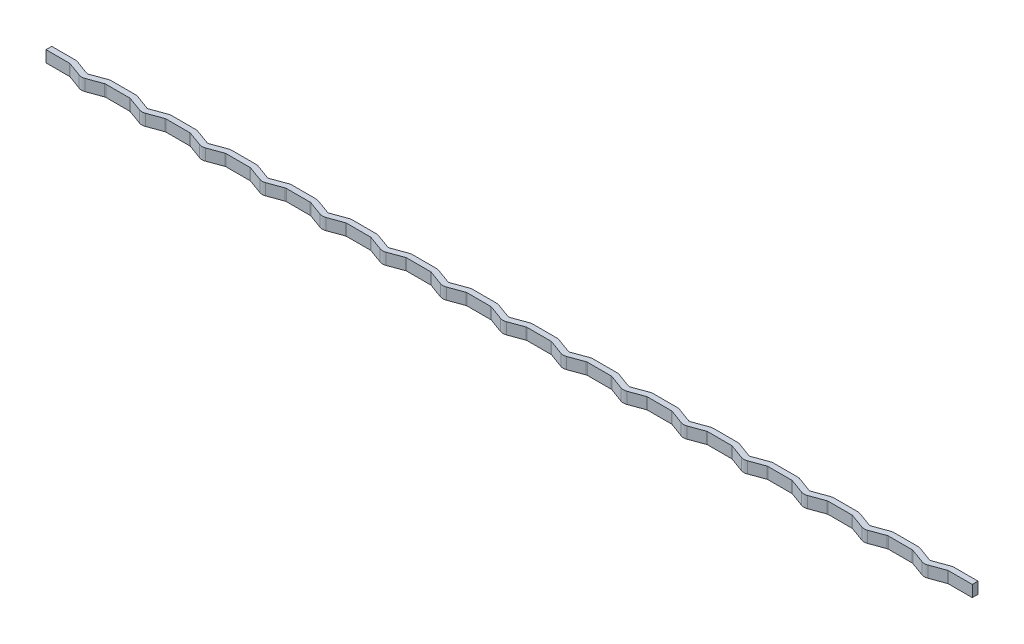
from build123d import *

# Parameters (mm, degrees)
BOSS_EXTRUDE1_DEPTH = 2
LPATTERN1_COUNT     = 15
LPATTERN1_PITCH     = 10.5
BOSS_EXTRUDE2_START = -157.5
SKETCH2_W           = 1
SKETCH2_H           = 2
BOSS_EXTRUDE2_DEPTH = 4.073673019


with BuildPart() as part:
    # Sketch1 → Boss-Extrude1 (new body)
    with BuildSketch(Plane(origin=(0, 0, 0), x_dir=(1, 0, 0), z_dir=(0, 1, 0))):
        with BuildLine():
            Line((0, -0.5), (4.073673019, -0.5))
            ThreePointArc((4.073673019, -0.5), (4.160497108, -0.507596123), (4.244683091, -0.53015369))
            Line((4.244683091, -0.53015369), (6.736969785, -1.437271862))
            ThreePointArc((6.736969785, -1.437271862), (7.25, -1.52773293), (7.763030215, -1.437271862))
            Line((7.763030215, -1.437271862), (10.255316909, -0.53015369))
            ThreePointArc((10.255316909, -0.53015369), (10.339502892, -0.507596123), (10.426326981, -0.5))
            Line((10.426326981, -0.5), (10.75, -0.5))
            Line((10.75, -0.5), (10.75, 0.5))
            Line((10.75, 0.5), (10.426326981, 0.5))
            ThreePointArc((10.426326981, 0.5), (10.165854714, 0.47721163), (9.913296766, 0.409538931))
            Line((9.913296766, 0.409538931), (7.421010072, -0.497579241))
            ThreePointArc((7.421010072, -0.497579241), (7.25, -0.52773293), (7.078989928, -0.497579241))
            Line((7.078989928, -0.497579241), (4.586703234, 0.409538931))
            ThreePointArc((4.586703234, 0.409538931), (4.334145286, 0.47721163), (4.073673019, 0.5))
            Line((4.073673019, 0.5), (0, 0.5))
            Line((0, 0.5), (0, -0.5))
        make_face()
    boss_extrude1 = extrude(amount=BOSS_EXTRUDE1_DEPTH)

    # LPattern1: Boss-Extrude1 ×15
    with Locations(*[(i * LPATTERN1_PITCH, 0, 0) for i in range(1, LPATTERN1_COUNT)]):
        add(boss_extrude1)

    # Sketch2 → Boss-Extrude2 (add)
    with BuildSketch(Plane.ZY.offset(BOSS_EXTRUDE2_START)):
        with Locations((0, 1)):
            Rectangle(SKETCH2_W, SKETCH2_H)
    extrude(amount=-BOSS_EXTRUDE2_DEPTH)


solid = part.part
